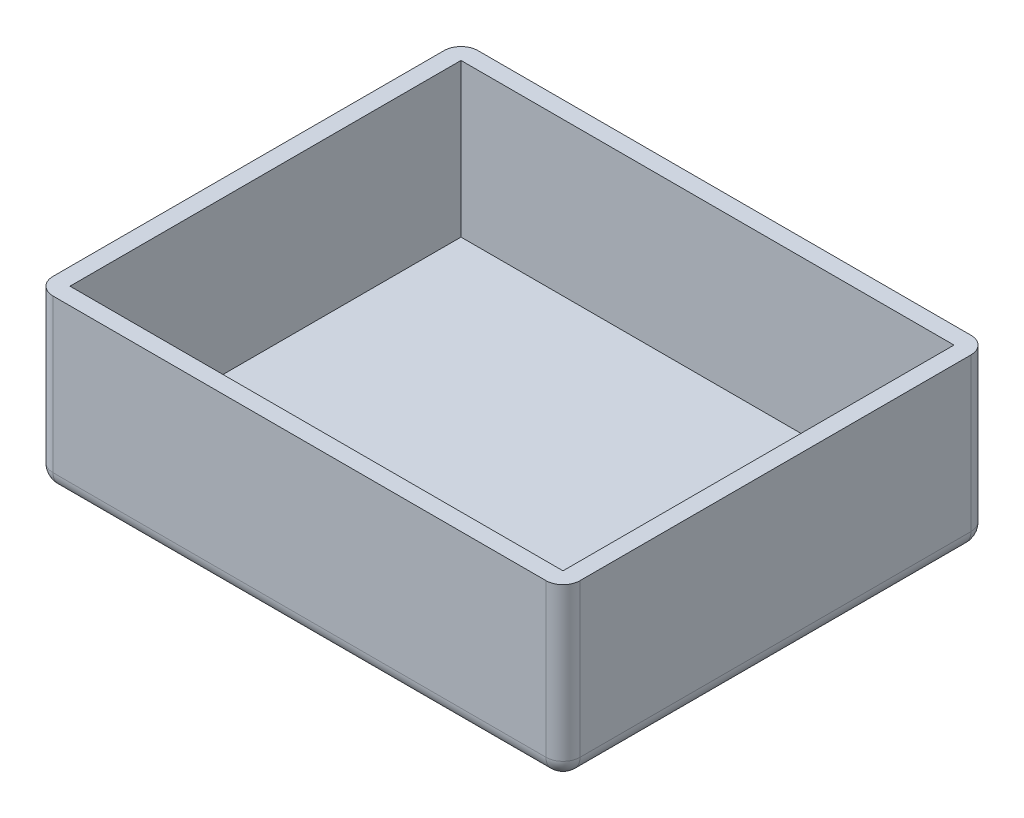
from build123d import *

# Parameters (mm, degrees)
ESQUISSE3_W             = 155
ESQUISSE3_H             = 125
BOSS_EXTRU_1_DEPTH      = 50
ESQUISSE4_W             = 145
ESQUISSE4_H             = 115
ENL_V_MAT_EXTRU_1_DEPTH = 45
CONG_1_R                = 5


with BuildPart() as part:
    # Esquisse3 → Boss.-Extru.1 (new body)
    with BuildSketch(Plane(origin=(0, 0, 0), x_dir=(1, 0, 0), z_dir=(0, 1, 0))):
        Rectangle(ESQUISSE3_W, ESQUISSE3_H)
    extrude(amount=BOSS_EXTRU_1_DEPTH)

    # Esquisse4 → Enlèv. mat.-Extru.1 (cut)
    with BuildSketch(Plane(origin=(0, 50, 0), x_dir=(1, 0, 0), z_dir=(0, 1, 0))):
        Rectangle(ESQUISSE4_W, ESQUISSE4_H)
    extrude(amount=-ENL_V_MAT_EXTRU_1_DEPTH, mode=Mode.SUBTRACT)

    # Congé1
    cong_1_edges = [part.edges().sort_by_distance(p)[0] for p in [
        (0, 0, -62.5),
        (77.5, 0, 0),
        (0, 0, 62.5),
        (-77.5, 0, 0),
        (-77.5, 25, -62.5),
        (77.5, 25, -62.5),
        (77.5, 25, 62.5),
        (-77.5, 25, 62.5),
    ]]
    fillet(cong_1_edges, radius=CONG_1_R)


solid = part.part
